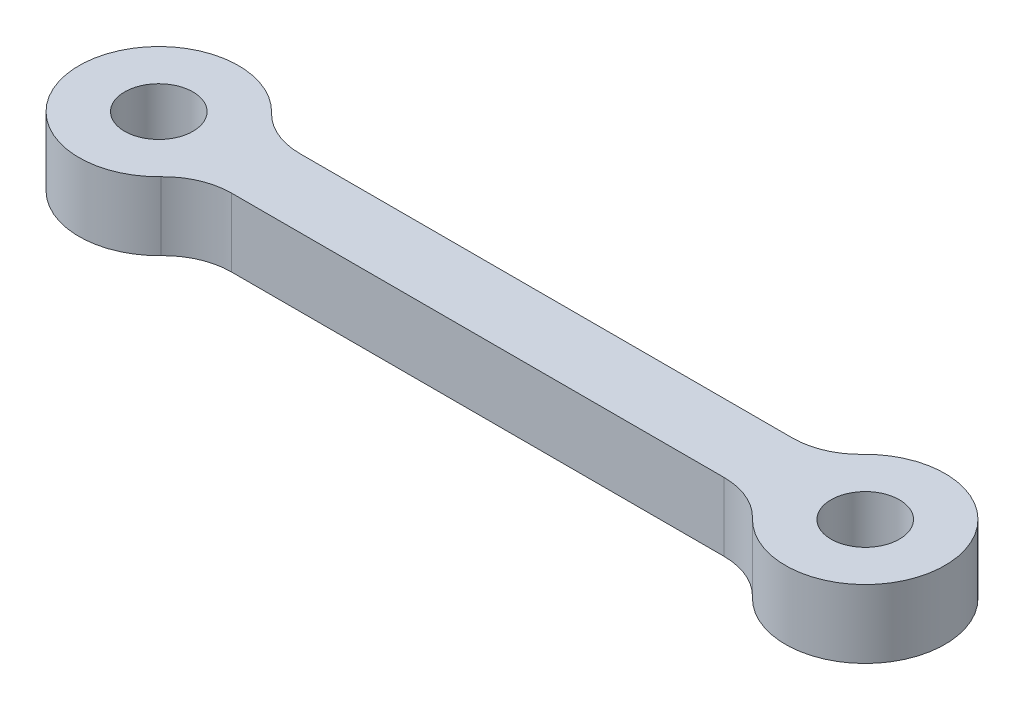
from build123d import *

# Parameters (mm, degrees)
SKETCH1_R           = 1.5
BOSS_EXTRUDE1_DEPTH = 3
FILLET1_R           = 3


with BuildPart() as part:
    # Sketch1 → Boss-Extrude1 (new body)
    with BuildSketch(Plane(origin=(0, 0, 0), x_dir=(1, 0, 0), z_dir=(0, 1, 0))):
        with BuildLine():
            Line((27.83772234, 1.5), (3.16227766, 1.5))
            ThreePointArc((3.16227766, 1.5), (-3.5, 0), (3.16227766, -1.5))
            Line((3.16227766, -1.5), (27.83772234, -1.5))
            ThreePointArc((27.83772234, -1.5), (34.5, 0), (27.83772234, 1.5))
        make_face()
        Circle(SKETCH1_R, mode=Mode.SUBTRACT)
        with Locations((31, 0)):
            Circle(SKETCH1_R, mode=Mode.SUBTRACT)
    extrude(amount=BOSS_EXTRUDE1_DEPTH)

    # Fillet1
    fillet1_edges = [part.edges().sort_by_distance(p)[0] for p in [
        (27.83772234, 1.5, 1.5),
        (3.16227766, 1.5, 1.5),
        (3.16227766, 1.5, -1.5),
        (27.83772234, 1.5, -1.5),
    ]]
    fillet(fillet1_edges, radius=FILLET1_R)


solid = part.part
